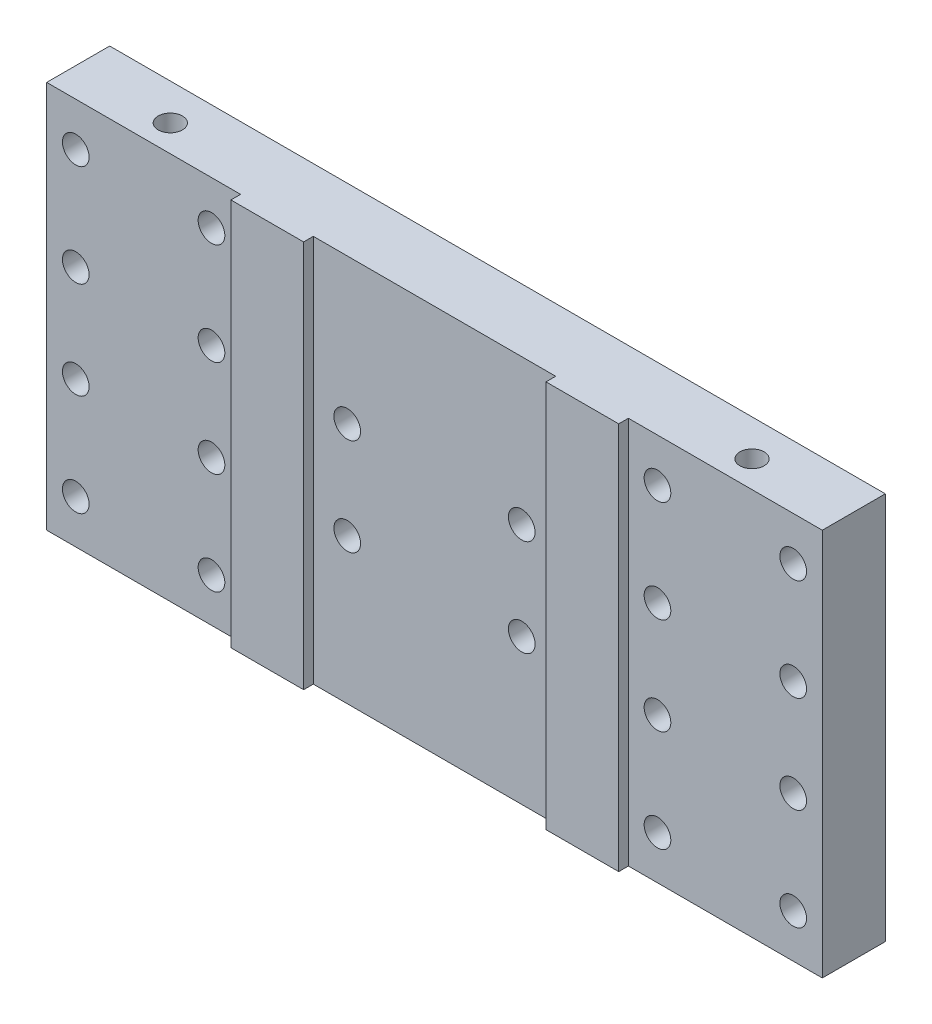
from build123d import *

# Parameters (mm, degrees)
SKETCH1_W                                           = 160
SKETCH1_H                                           = 80
BOSS_EXTRUDE1_DEPTH                                 = 15
CBORE_FOR_M5_HEX_SOCKET_HEAD_CAP_SCREW1_D           = 5.5
CBORE_FOR_M5_HEX_SOCKET_HEAD_CAP_SCREW1_CBORE_D     = 10
CBORE_FOR_M5_HEX_SOCKET_HEAD_CAP_SCREW1_CBORE_DEPTH = 5.4
M6_TAPPED_HOLE1_D                                   = 5
SKETCH15_W                                          = 40
SKETCH15_H                                          = 80
SKETCH15_W_2                                        = 50
CUT_EXTRUDE1_DEPTH                                  = 2


with BuildPart() as part:
    # Sketch1 → Boss-Extrude1 (new body)
    with BuildSketch(Plane.XY):
        Rectangle(SKETCH1_W, SKETCH1_H)
    extrude(amount=BOSS_EXTRUDE1_DEPTH)

    # CBORE for M5 Hex Socket Head Cap Screw1 (through all)
    with Locations(Plane(origin=(74, 31, 0), x_dir=(-1, 0, 0), z_dir=(0, 0, -1))):
        with Locations((0, 0), (28, 0), (0, -21), (28, -21), (0, -41), (0, -62), (28, -41), (28, -62), (56, -41), (56, -21), (92, -21), (92, -41), (120, 0), (120, -21), (148, 0), (148, -21), (120, -41), (120, -62), (148, -41), (148, -62)):
            CounterBoreHole(CBORE_FOR_M5_HEX_SOCKET_HEAD_CAP_SCREW1_D / 2, CBORE_FOR_M5_HEX_SOCKET_HEAD_CAP_SCREW1_CBORE_D / 2, CBORE_FOR_M5_HEX_SOCKET_HEAD_CAP_SCREW1_CBORE_DEPTH)

    # M6 Tapped Hole1 (through all)
    with Locations(Plane(origin=(-60, -40, 7.5), x_dir=(0, 0, -1), z_dir=(0, -1, 0))):
        with Locations((0, 0), (0, 120)):
            Hole(M6_TAPPED_HOLE1_D / 2)

    # Sketch15 → Cut-Extrude1 (cut)
    with BuildSketch(Plane.XY.offset(15)):
        with Locations((-60, 0)):
            Rectangle(SKETCH15_W, SKETCH15_H)
        with Locations((60, 0)):
            Rectangle(SKETCH15_W, SKETCH15_H)
        Rectangle(SKETCH15_W_2, SKETCH15_H)
    extrude(amount=-CUT_EXTRUDE1_DEPTH, mode=Mode.SUBTRACT)


solid = part.part
